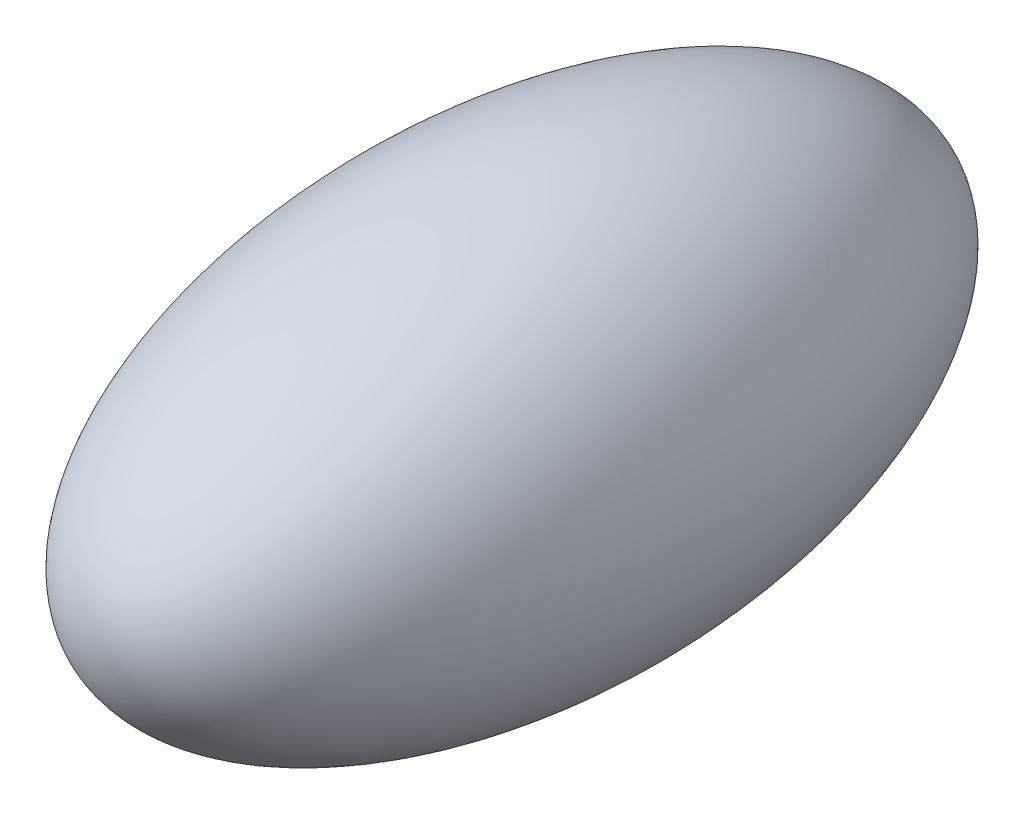
from build123d import *


with BuildPart() as part:
    # Sketch1 one side → Revolve2 (revolve)
    with BuildSketch(Plane(origin=(0, 0, 0), x_dir=(0, 0, -1), z_dir=(1, 0, 0))):
        with BuildLine():
            Line((-12.7, 0), (12.7, 0))
            add(Edge.make_bspline(
                [(12.7, 0), (12.7, 6.35), (0, 6.35), (-12.7, 6.35), (-12.7, 0)],
                knots=[0, 0, 0, 1.570796327, 1.570796327, 3.141592654, 3.141592654, 3.141592654], degree=2, weights=[1, 0.707106781, 1, 0.707106781, 1]))
        make_face()
    revolve(axis=Axis((0, 0, 12.7), (0, 0, -1)))


solid = part.part
